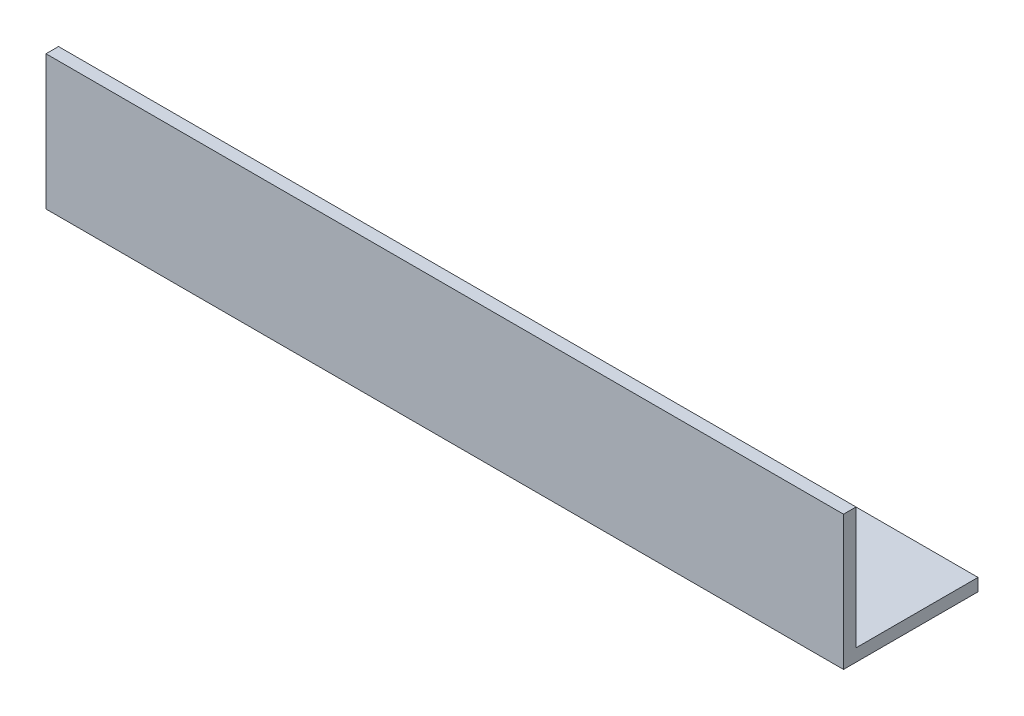
from build123d import *

# Parameters (mm, degrees)
EXTRUDE_1_DEPTH     = 255
SKETCH_2_R          = 5
CUT_EXTRUDE_1_DEPTH = 44


with BuildPart() as part:
    # Эскиз1 → Вытянуть-Тонкостенный1 (new body)
    with BuildSketch(Plane(origin=(0, 0, 0), x_dir=(0, 0, -1), z_dir=(1, 0, 0))):
        Polygon((0, 43), (0, 0), (43, 0), (43, 4), (4, 4), (4, 43), align=None)
    extrude(amount=EXTRUDE_1_DEPTH)

    # Эскиз2 → Вырез-Вытянуть1 (cut, through all)
    with BuildSketch(Plane.XZ):
        with Locations((80, -23)):
            Circle(SKETCH_2_R)
        with Locations((180, -23)):
            Circle(SKETCH_2_R)
    extrude(amount=-CUT_EXTRUDE_1_DEPTH, mode=Mode.SUBTRACT)


solid = part.part
